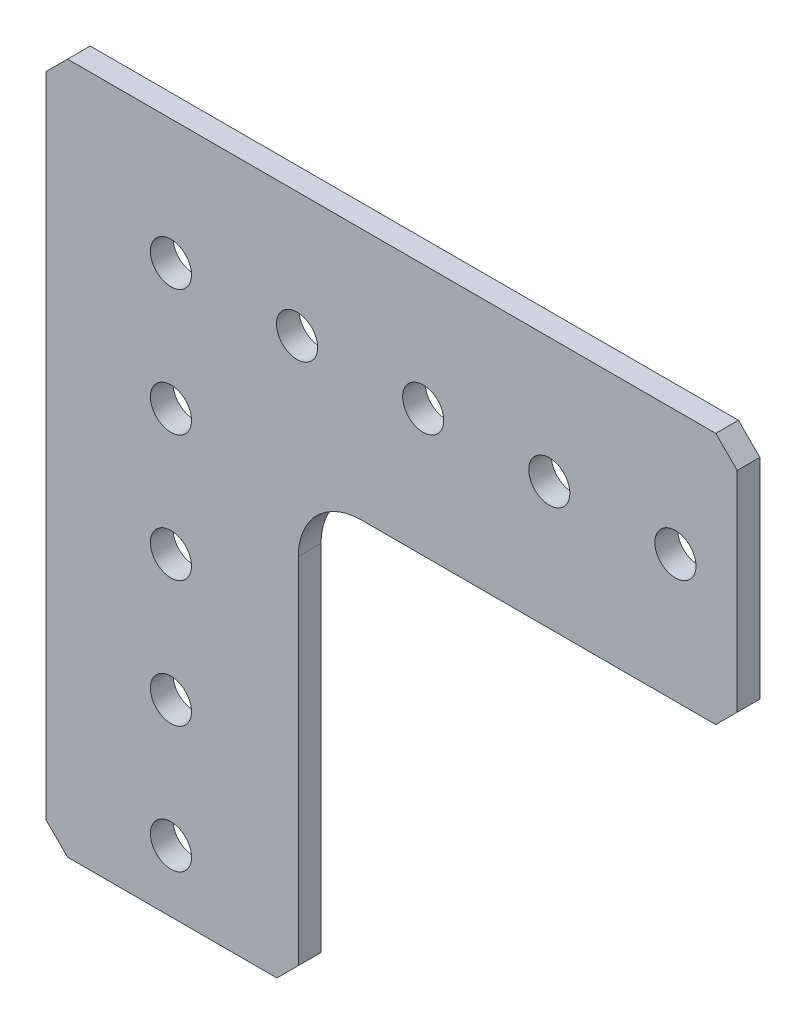
from build123d import *

# Parameters (mm, degrees)
SKETCH1_R           = 2.0701
BOSS_EXTRUDE1_DEPTH = 2.286


with BuildPart() as part:
    # Sketch1 → Boss-Extrude1 (new body)
    with BuildSketch(Plane(origin=(0, 0, 0), x_dir=(-1, 0, 0), z_dir=(0, 0, -1))):
        with BuildLine():
            Line((10.414, 12.573), (-54.864, 12.573))
            Line((-54.864, 12.573), (-57.023, 10.414))
            Line((-57.023, 10.414), (-57.023, -10.668))
            Line((-57.023, -10.668), (-54.864, -12.827))
            Line((-54.864, -12.827), (-19.177, -12.827))
            ThreePointArc((-19.177, -12.827), (-14.686871939, -14.686871939), (-12.827, -19.177))
            Line((-12.827, -19.177), (-12.827, -54.864))
            Line((-12.827, -54.864), (-10.668, -57.023))
            Line((-10.668, -57.023), (10.414, -57.023))
            Line((10.414, -57.023), (12.573, -54.864))
            Line((12.573, -54.864), (12.573, 10.414))
            Line((12.573, 10.414), (10.414, 12.573))
        make_face()
        with Locations((0, -50.8)):
            Circle(SKETCH1_R, mode=Mode.SUBTRACT)
        with Locations((0, -25.4)):
            Circle(SKETCH1_R, mode=Mode.SUBTRACT)
        with Locations((-38.1, 0)):
            Circle(SKETCH1_R, mode=Mode.SUBTRACT)
        with Locations((-12.7, 0)):
            Circle(SKETCH1_R, mode=Mode.SUBTRACT)
        Circle(SKETCH1_R, mode=Mode.SUBTRACT)
        with Locations((-25.4, 0)):
            Circle(SKETCH1_R, mode=Mode.SUBTRACT)
        with Locations((0, -12.7)):
            Circle(SKETCH1_R, mode=Mode.SUBTRACT)
        with Locations((0, -38.1)):
            Circle(SKETCH1_R, mode=Mode.SUBTRACT)
        with Locations((-50.8, 0)):
            Circle(SKETCH1_R, mode=Mode.SUBTRACT)
    extrude(amount=-BOSS_EXTRUDE1_DEPTH)


solid = part.part
